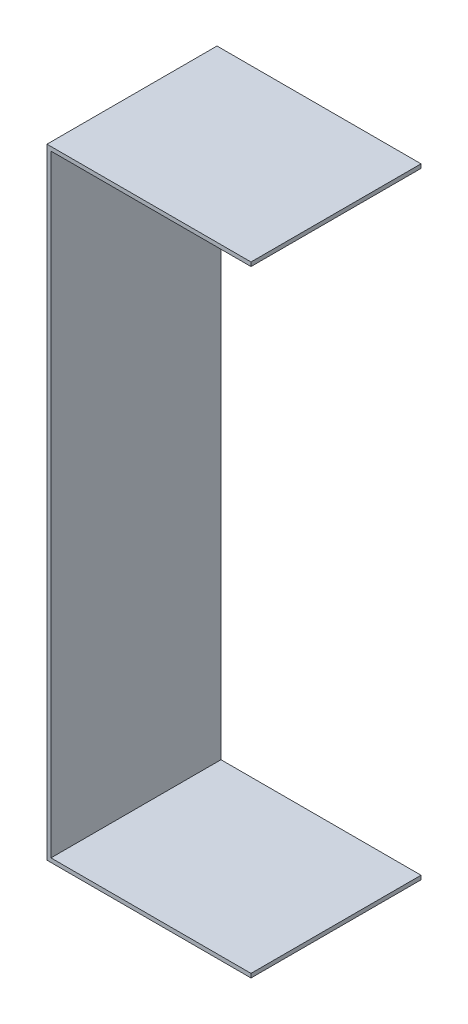
from build123d import *

# Parameters (mm, degrees)
BOSS_EXTRUDE1_DEPTH = 85


with BuildPart() as part:
    # Sketch1 → Boss-Extrude1 (new body)
    with BuildSketch(Plane.XY):
        Polygon((0, 0), (0, 306), (100, 306), (100, 308), (-2, 308), (-2, -2), (100, -2), (100, 0), align=None)
    extrude(amount=BOSS_EXTRUDE1_DEPTH)


solid = part.part
